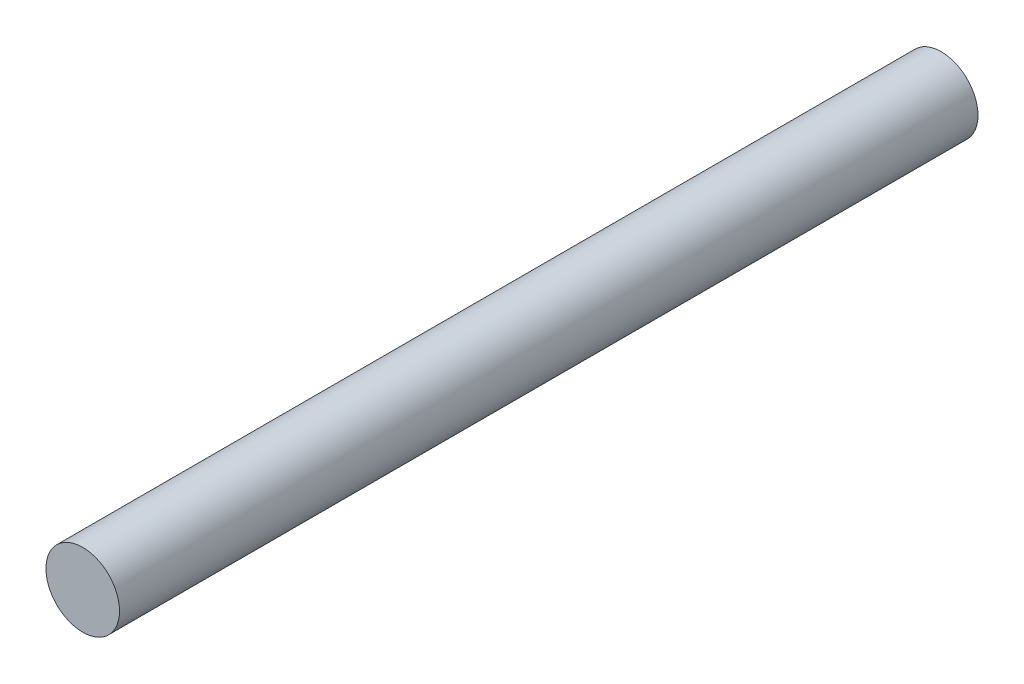
from build123d import *

# Parameters (mm, degrees)
SKETCH1_R           = 3
BOSS_EXTRUDE1_DEPTH = 70


with BuildPart() as part:
    # Sketch1 → Boss-Extrude1 (new body)
    with BuildSketch(Plane.XY):
        Circle(SKETCH1_R)
    extrude(amount=BOSS_EXTRUDE1_DEPTH)


solid = part.part
